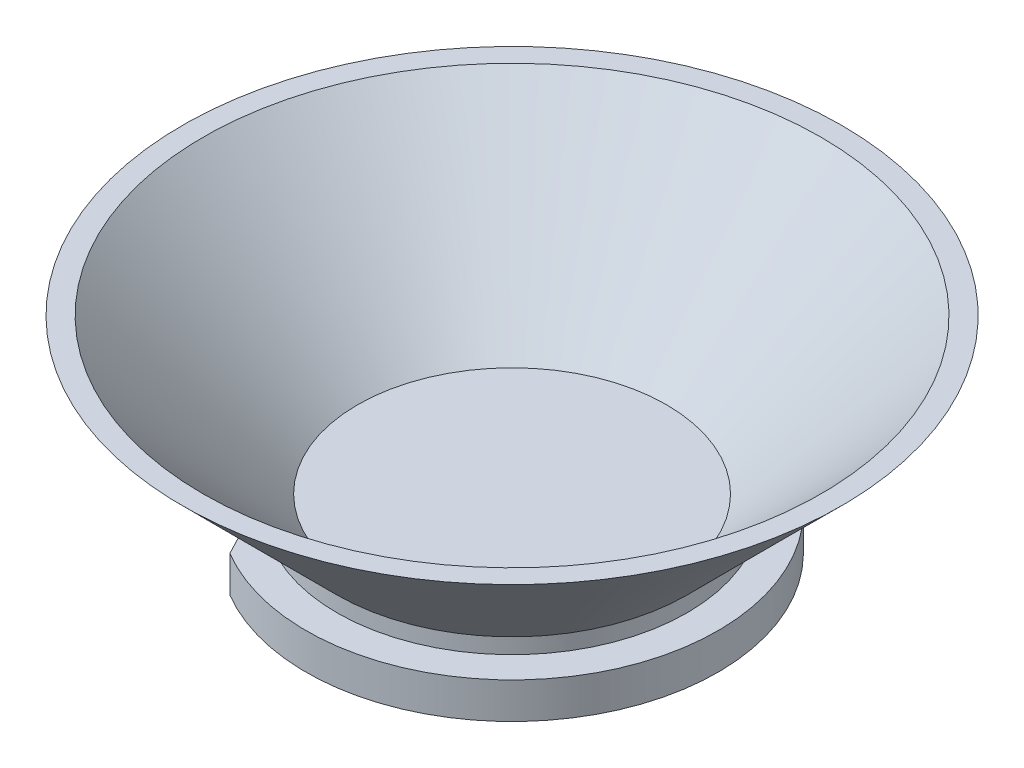
from build123d import *

# Parameters (mm, degrees)
ENL_V_MAT_EXTRU_1_DEPTH = 15


with BuildPart() as part:
    # Esquisse1 → Révolution1 (revolve)
    with BuildSketch(Plane.XY, mode=Mode.PRIVATE) as r_volution1_sk:
        Polygon((0, 0), (-60, 0), (-120, 60), (-128, 60), (-68, 0), (-68, -6), (-80, -6), (-80, -20), (0, -20), align=None)
    revolve(r_volution1_sk.sketch.rotate(Axis((0, -20, 0), (0, 1, 0)), 270), axis=Axis((0, -20, 0), (0, 1, 0)))  # turned: the seam where the file's is

    # Esquisse8 → Enlèv. mat.-Extru.1 (cut, through all)
    with BuildSketch(Plane(origin=(0, -6, 0), x_dir=(1, 0, 0), z_dir=(0, 1, 0))):
        Polygon((-79.781170075, 5.913112665), (-40.797993833, -68.815141497), (-98.313445601, -98.818987004), (-137.296621843, -24.090732842), align=None)
    extrude(amount=-ENL_V_MAT_EXTRU_1_DEPTH, mode=Mode.SUBTRACT)


solid = part.part
